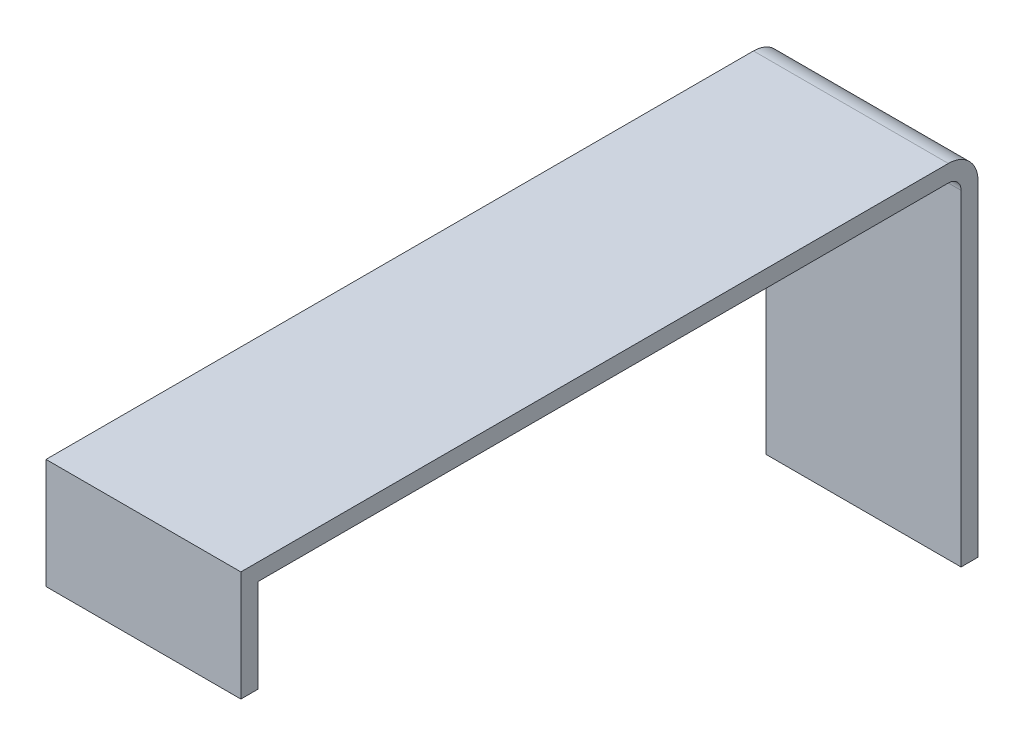
from build123d import *

# Parameters (mm, degrees)
SKETCH1_W           = 23
SKETCH1_H           = 87
BOSS_EXTRUDE1_DEPTH = 42
FILLET1_R           = 3.5
CUT_EXTRUDE1_DEPTH  = 24
SKETCH3_W           = 2
SKETCH3_H           = 40
CUT_EXTRUDE3_DEPTH  = 24
SKETCH4_W           = 83
SKETCH4_H           = 2
CUT_EXTRUDE5_DEPTH  = 24
SKETCH6_W           = 23
SKETCH6_H           = 2
BOSS_EXTRUDE2_DEPTH = 11


with BuildPart() as part:
    # Sketch1 → Boss-Extrude1 (new body)
    with BuildSketch(Plane(origin=(0, 0, 0), x_dir=(1, 0, 0), z_dir=(0, 1, 0))):
        with Locations((14.807125307, -11.663390663)):
            Rectangle(SKETCH1_W, SKETCH1_H)
    extrude(amount=BOSS_EXTRUDE1_DEPTH)

    # Fillet1
    fillet1_edges = [part.edges().sort_by_distance(p)[0] for p in [
        (14.807125307, 42, -31.836609337),
    ]]
    fillet(fillet1_edges, radius=FILLET1_R)

    # Sketch2 → Cut-Extrude1 (cut, through all)
    with BuildSketch(Plane(origin=(26.307125307, 0, 0), x_dir=(0, 0, -1), z_dir=(1, 0, 0))):
        with BuildLine():
            Line((29.836609337, 2), (29.836609337, 38.5))
            ThreePointArc((29.836609337, 38.5), (29.397269508, 39.560660172), (28.336609337, 40))
            Line((28.336609337, 40), (-53.163390663, 40))
            Line((-53.163390663, 40), (-53.163390663, 2))
            Line((-53.163390663, 2), (29.836609337, 2))
        make_face()
    extrude(amount=-CUT_EXTRUDE1_DEPTH, mode=Mode.SUBTRACT)

    # Sketch3 → Cut-Extrude3 (cut, through all)
    with BuildSketch(Plane(origin=(26.307125307, 0, 0), x_dir=(0, 0, -1), z_dir=(1, 0, 0))):
        with Locations((-54.163390663, 20)):
            Rectangle(SKETCH3_W, SKETCH3_H)
    extrude(amount=-CUT_EXTRUDE3_DEPTH, mode=Mode.SUBTRACT)

    # Sketch4 → Cut-Extrude5 (cut, through all)
    with BuildSketch(Plane(origin=(26.307125307, 0, 0), x_dir=(0, 0, -1), z_dir=(1, 0, 0))):
        with Locations((-11.663390663, 1)):
            Rectangle(SKETCH4_W, SKETCH4_H)
    extrude(amount=-CUT_EXTRUDE5_DEPTH, mode=Mode.SUBTRACT)

    # Sketch6 → Boss-Extrude2 (add)
    with BuildSketch(Plane.XZ.offset(-40)):
        with Locations((14.807125307, 54.163390663)):
            Rectangle(SKETCH6_W, SKETCH6_H)
    extrude(amount=BOSS_EXTRUDE2_DEPTH)


solid = part.part
